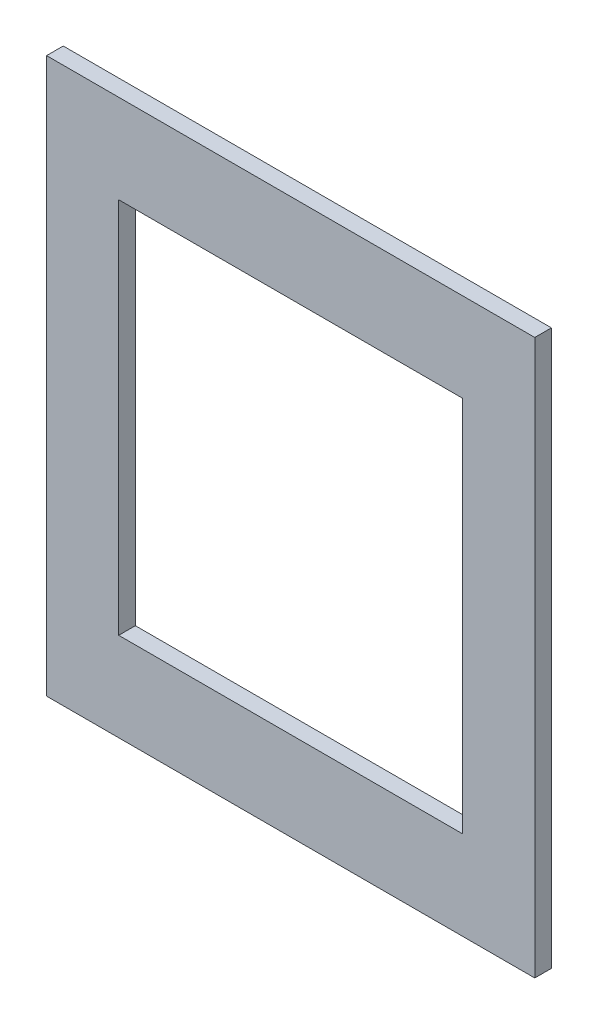
from build123d import *

# Parameters (mm, degrees)
SKETCH1_W           = 44
SKETCH1_H           = 50
SKETCH1_W_2         = 31
SKETCH1_H_2         = 34
BOSS_EXTRUDE1_DEPTH = 1.5


with BuildPart() as part:
    # Sketch1 → Boss-Extrude1 (new body)
    with BuildSketch(Plane.XY):
        Rectangle(SKETCH1_W, SKETCH1_H)
        Rectangle(SKETCH1_W_2, SKETCH1_H_2, mode=Mode.SUBTRACT)
    extrude(amount=BOSS_EXTRUDE1_DEPTH)


solid = part.part
